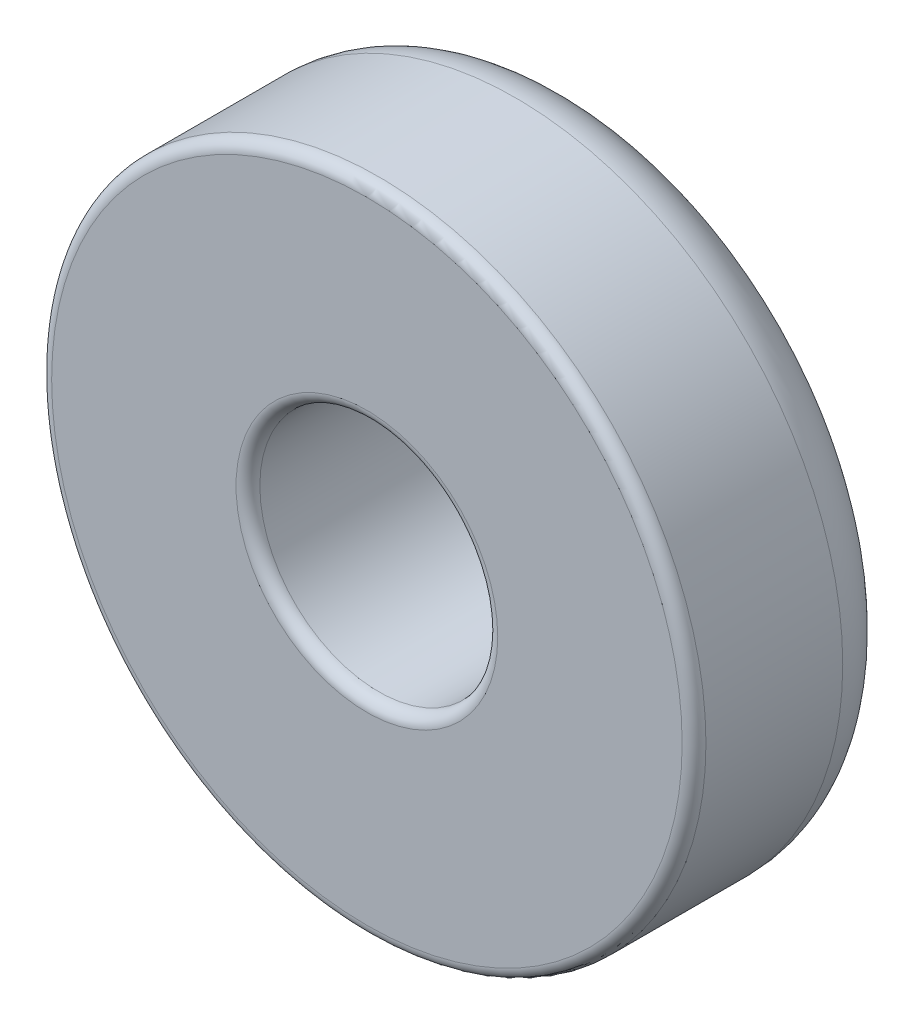
from build123d import *

# Parameters (mm, degrees)
SKETCH1_R           = 2.75
SKETCH1_R_2         = 1
EXTRUDE_THIN1_DEPTH = 1.75
FILLET1_R           = 0.5
FILLET2_R           = 0.1
SCALE1_SCALE        = 10


with BuildPart() as part:
    # Sketch1 → Extrude-Thin1 (new body)
    with BuildSketch(Plane.XY):
        Circle(SKETCH1_R)
        Circle(SKETCH1_R_2, mode=Mode.SUBTRACT)
    extrude(amount=EXTRUDE_THIN1_DEPTH)

    # Fillet1
    fillet1_edges = [part.edges().sort_by_distance(p)[0] for p in [
        (-2.75, 0, 0),
    ]]
    fillet(fillet1_edges, radius=FILLET1_R)

    # Fillet2
    fillet2_edges = [part.edges().sort_by_distance(p)[0] for p in [
        (-1, 0, 0),
        (-2.75, 0, 1.75),
        (-1, 0, 1.75),
    ]]
    fillet(fillet2_edges, radius=FILLET2_R)


with BuildPart() as part_1:
    # Scale1: scaled about (0, 0, 0.893384529)
    add(part.part.scale(SCALE1_SCALE).moved(Location((0, 0, -8.040460761))))


solid = part_1.part
